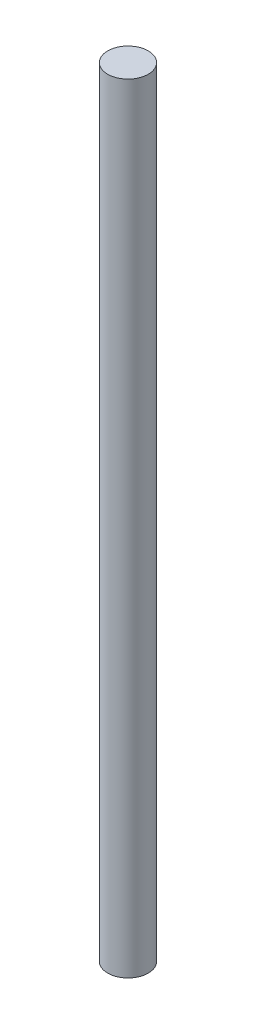
from build123d import *

# Parameters (mm, degrees)
SKETCH1_R           = 15.875
BOSS_EXTRUDE1_DEPTH = 609.6


with BuildPart() as part:
    # Sketch1 → Boss-Extrude1 (new body)
    with BuildSketch(Plane(origin=(0, 0, 0), x_dir=(1, 0, 0), z_dir=(0, 1, 0))):
        Circle(SKETCH1_R)
    extrude(amount=BOSS_EXTRUDE1_DEPTH)


solid = part.part
